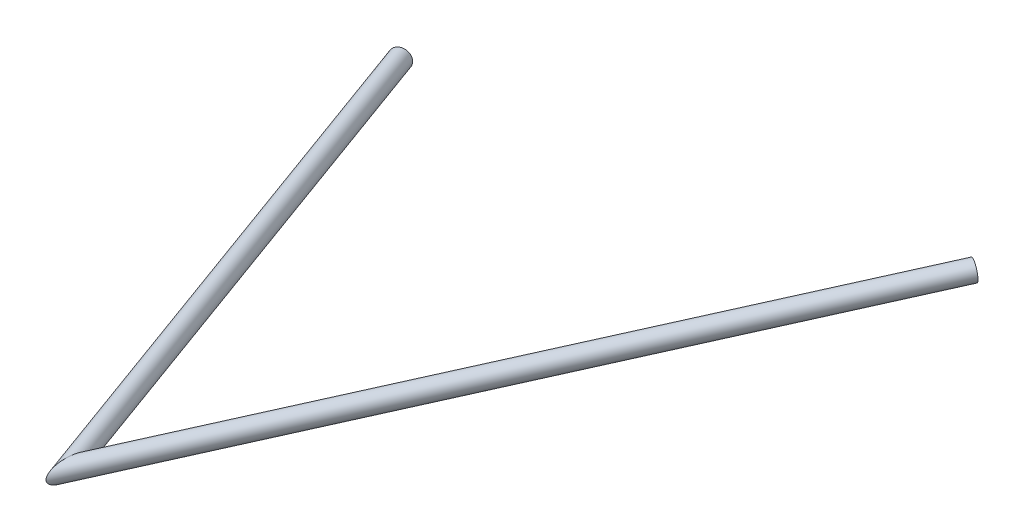
from build123d import *

# Parameters (mm, degrees)
SKETCH1_R                                 = 9.525
SKETCH1_R_2                               = 8.525
PIPE_STANDARD_S40_PIPE_1_SCH_40_1_DEPTH   = 622.589065093
SKETCH1_ON_SEGMENT_2_R                    = 9.525
SKETCH1_ON_SEGMENT_2_R_2                  = 8.525
PIPE_STANDARD_S40_PIPE_1_SCH_40_1_2_DEPTH = 702.032675189


with BuildPart() as part:
    # Sketch1 → Pipe standard s40 PIPE 1 SCH 40_1 (new body)
    with BuildSketch(Plane(origin=(-182.037028919, -70.956246539, -535.059499451), x_dir=(0.9304472685626328, -0.008381115739210878, -0.36632995690129105), z_dir=(0.3663299569012911, 0.044142820908401624, 0.9294373427181346))):
        Circle(SKETCH1_R)
        Circle(SKETCH1_R_2, mode=Mode.SUBTRACT)
    extrude(amount=PIPE_STANDARD_S40_PIPE_1_SCH_40_1_DEPTH)

    # Pipe standard s40 PIPE 1 SCH 40_1 mitre
    split(bisect_by=Plane(origin=(35.323609273, -44.764253383, 16.418997373), x_dir=(0.126815049, -0.99192638, 0), z_dir=(-0.989691413, -0.126529315, -0.067091272)), keep=Keep.TOP)


with BuildPart() as body_2:
    # Sketch1 on segment 2 (carried to segment 2) → Pipe standard s40 PIPE 1 SCH 40_1 2 (new body)
    with BuildSketch(Plane(origin=(21.118015273, -46.659104037, 41.908834566), x_dir=(-0.841531219, -0.234923673, -0.486452542), z_dir=(0.485786645, 0.064797934, -0.871672279))):
        Circle(SKETCH1_ON_SEGMENT_2_R)
        Circle(SKETCH1_ON_SEGMENT_2_R_2, mode=Mode.SUBTRACT)
    extrude(amount=PIPE_STANDARD_S40_PIPE_1_SCH_40_1_2_DEPTH)

    # Pipe standard s40 PIPE 1 SCH 40_1 2 mitr
    split(bisect_by=Plane(origin=(35.323609273, -44.764253383, 16.418997373), x_dir=(-0.126815049, 0.99192638, 0), z_dir=(0.989691413, 0.126529315, 0.067091272)), keep=Keep.TOP)


solid = Compound([part.part, body_2.part])
